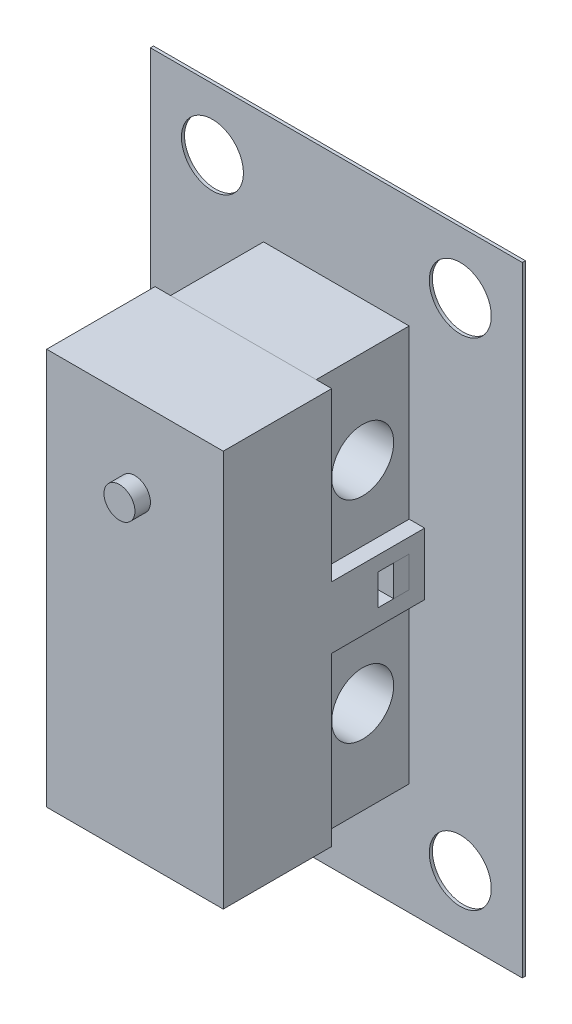
from build123d import *

# Parameters (mm, degrees)
SKETCH1_W            = 5.7
SKETCH1_H            = 12.8
BOSS_EXTRUDE2_DEPTH  = 6.5
SKETCH3_R            = 0.575
BOSS_EXTRUDE3_DEPTH  = 0.5
SKETCH7_W            = 3
SKETCH7_H            = 12.8
CUT_EXTRUDE1_DEPTH   = 0.5
SKETCH8_W            = 3
SKETCH8_H            = 12.8
CUT_EXTRUDE2_DEPTH   = 0.5
SKETCH9_R            = 1
CUT_EXTRUDE3_DEPTH   = 6.2
SKETCH10_W           = 6
SKETCH10_H           = 2
BOSS_EXTRUDE4_DEPTH  = 0.5
SKETCH11_W           = 6
SKETCH11_H           = 2
BOSS_EXTRUDE6_DEPTH  = 0.5
SKETCH13_W           = 4.7
SKETCH13_H           = 3
CUT_EXTRUDE4_DEPTH   = 13.8
SKETCH16_W           = 4.7
SKETCH16_H           = 3
BOSS_EXTRUDE8_DEPTH  = 12.8
SKETCH17_R           = 1
CUT_EXTRUDE5_DEPTH   = 6.2
SKETCH18_R           = 0.575
CUT_EXTRUDE6_DEPTH   = 0.5
SKETCH19_R           = 0.5
BOSS_EXTRUDE9_DEPTH  = 0.5
SKETCH20_W           = 1
SKETCH20_H           = 1
CUT_EXTRUDE8_DEPTH   = 0.5
SKETCH21_W           = 0.5
SKETCH21_H           = 1
BOSS_EXTRUDE11_DEPTH = 0.5
SKETCH22_W           = 1
SKETCH22_H           = 1
CUT_EXTRUDE9_DEPTH   = 0.5
SKETCH23_W           = 0.5
SKETCH23_H           = 1
BOSS_EXTRUDE13_DEPTH = 0.5
SKETCH28_W           = 12
SKETCH28_H           = 20
BOSS_EXTRUDE15_DEPTH = 0.1
SKETCH29_R           = 1
CUT_EXTRUDE10_DEPTH  = 10.1


with BuildPart() as part:
    # Sketch1 → Boss-Extrude2 (new body)
    with BuildSketch(Plane.XY):
        with Locations((4.821797151, 12.683595414)):
            Rectangle(SKETCH1_W, SKETCH1_H)
    extrude(amount=BOSS_EXTRUDE2_DEPTH)

    # Sketch3 → Boss-Extrude3 (add)
    with BuildSketch(Plane.XY.offset(6.5)):
        with Locations((4.821797151, 16.601773498)):
            Circle(SKETCH3_R)
    extrude(amount=BOSS_EXTRUDE3_DEPTH)

    # Sketch7 → Cut-Extrude1 (cut)
    with BuildSketch(Plane(origin=(7.671797151, 0, 0), x_dir=(0, 0, -1), z_dir=(1, 0, 0))):
        with Locations((-1.5, 12.683595414)):
            Rectangle(SKETCH7_W, SKETCH7_H)
    extrude(amount=-CUT_EXTRUDE1_DEPTH, mode=Mode.SUBTRACT)

    # Sketch8 → Cut-Extrude2 (cut)
    with BuildSketch(Plane.ZY.offset(-1.971797151)):
        with Locations((1.5, 12.683595414)):
            Rectangle(SKETCH8_W, SKETCH8_H)
    extrude(amount=-CUT_EXTRUDE2_DEPTH, mode=Mode.SUBTRACT)

    # Sketch9 → Cut-Extrude3 (cut, through all)
    with BuildSketch(Plane(origin=(7.171797151, 0, 0), x_dir=(0, 0, -1), z_dir=(1, 0, 0))):
        with Locations((-1.661401628, 9.783595414)):
            Circle(SKETCH9_R)
        with Locations((-1.661401628, 15.583595414)):
            Circle(SKETCH9_R)
    extrude(amount=-CUT_EXTRUDE3_DEPTH, mode=Mode.SUBTRACT)

    # Sketch10 → Boss-Extrude4 (add)
    with BuildSketch(Plane.ZY.offset(-1.971797151)):
        with Locations((3, 12.683595414)):
            Rectangle(SKETCH10_W, SKETCH10_H)
    extrude(amount=-BOSS_EXTRUDE4_DEPTH)

    # Sketch11 → Boss-Extrude6 (add)
    with BuildSketch(Plane(origin=(7.671797151, 0, 0), x_dir=(0, 0, -1), z_dir=(1, 0, 0))):
        with Locations((-3, 12.683595414)):
            Rectangle(SKETCH11_W, SKETCH11_H)
    extrude(amount=-BOSS_EXTRUDE6_DEPTH)

    # Sketch13 → Cut-Extrude4 (cut, through all)
    with BuildSketch(Plane(origin=(0, 19.083595414, 0), x_dir=(1, 0, 0), z_dir=(0, 1, 0))):
        with Locations((4.821797151, -1.5)):
            Rectangle(SKETCH13_W, SKETCH13_H)
    extrude(amount=-CUT_EXTRUDE4_DEPTH, mode=Mode.SUBTRACT)

    # Sketch18 → Cut-Extrude6 (cut)
    with BuildSketch(Plane.XY.offset(7)):
        with Locations((4.821797151, 16.601773498)):
            Circle(SKETCH18_R)
    extrude(amount=-CUT_EXTRUDE6_DEPTH, mode=Mode.SUBTRACT)

    # Sketch20 → Cut-Extrude8 (cut)
    with BuildSketch(Plane(origin=(7.671797151, 0, 0), x_dir=(0, 0, -1), z_dir=(1, 0, 0))):
        with Locations((-1, 12.709770328)):
            Rectangle(SKETCH20_W, SKETCH20_H)
    extrude(amount=-CUT_EXTRUDE8_DEPTH, mode=Mode.SUBTRACT)

    # Sketch22 → Cut-Extrude9 (cut)
    with BuildSketch(Plane.ZY.offset(-1.971797151)):
        with Locations((1, 12.639196458)):
            Rectangle(SKETCH22_W, SKETCH22_H)
    extrude(amount=-CUT_EXTRUDE9_DEPTH, mode=Mode.SUBTRACT)


with BuildPart() as body_2:
    # Sketch16 → Boss-Extrude8 (new body)
    with BuildSketch(Plane(origin=(0, 19.083595414, 0), x_dir=(1, 0, 0), z_dir=(0, 1, 0))):
        with Locations((4.821797151, -1.5)):
            Rectangle(SKETCH16_W, SKETCH16_H)
    extrude(amount=-BOSS_EXTRUDE8_DEPTH)

    # Sketch17 → Cut-Extrude5 (cut, through all)
    with BuildSketch(Plane(origin=(7.171797151, 0, 0), x_dir=(0, 0, -1), z_dir=(1, 0, 0))):
        with Locations((-1.5, 16.083595414)):
            Circle(SKETCH17_R)
        with Locations((-1.5, 9.283595414)):
            Circle(SKETCH17_R)
    extrude(amount=-CUT_EXTRUDE5_DEPTH, mode=Mode.SUBTRACT)


with BuildPart() as body_3:
    # Sketch19 → Boss-Extrude9 (new body)
    with BuildSketch(Plane.XY.offset(6.5)):
        with Locations((4.821797151, 16.476820211)):
            Circle(SKETCH19_R)
    extrude(amount=BOSS_EXTRUDE9_DEPTH)


with BuildPart() as body_4:
    # Sketch21 → Boss-Extrude11 (new body)
    with BuildSketch(Plane(origin=(7.171797151, 0, 0), x_dir=(0, 0, -1), z_dir=(1, 0, 0))):
        with Locations((-0.75, 12.709770328)):
            Rectangle(SKETCH21_W, SKETCH21_H)
    extrude(amount=BOSS_EXTRUDE11_DEPTH)


with BuildPart() as body_5:
    # Sketch23 → Boss-Extrude13 (new body)
    with BuildSketch(Plane.ZY.offset(-2.471797151)):
        with Locations((0.75, 12.639196458)):
            Rectangle(SKETCH23_W, SKETCH23_H)
    extrude(amount=BOSS_EXTRUDE13_DEPTH)


with BuildPart() as body_6:
    # Sketch28 → Boss-Extrude15 (new body)
    with BuildSketch(Plane(origin=(0, 0, 0), x_dir=(-1, 0, 0), z_dir=(0, 0, -1))):
        with Locations((-4.821797151, 12.683595414)):
            Rectangle(SKETCH28_W, SKETCH28_H)
    extrude(amount=BOSS_EXTRUDE15_DEPTH)

    # Sketch29 → Cut-Extrude10 (cut)
    with BuildSketch(Plane(origin=(0, 0, -0.1), x_dir=(-1, 0, 0), z_dir=(0, 0, -1))):
        with Locations((-8.821797151, 20.683595414)):
            Circle(SKETCH29_R)
        with Locations((-8.821797151, 4.683595414)):
            Circle(SKETCH29_R)
        with Locations((-0.821797151, 4.683595414)):
            Circle(SKETCH29_R)
        with Locations((-0.821797151, 20.683595414)):
            Circle(SKETCH29_R)
    extrude(amount=-CUT_EXTRUDE10_DEPTH, mode=Mode.SUBTRACT)


solid = Compound([part.part, body_2.part, body_3.part, body_4.part, body_5.part, body_6.part])
